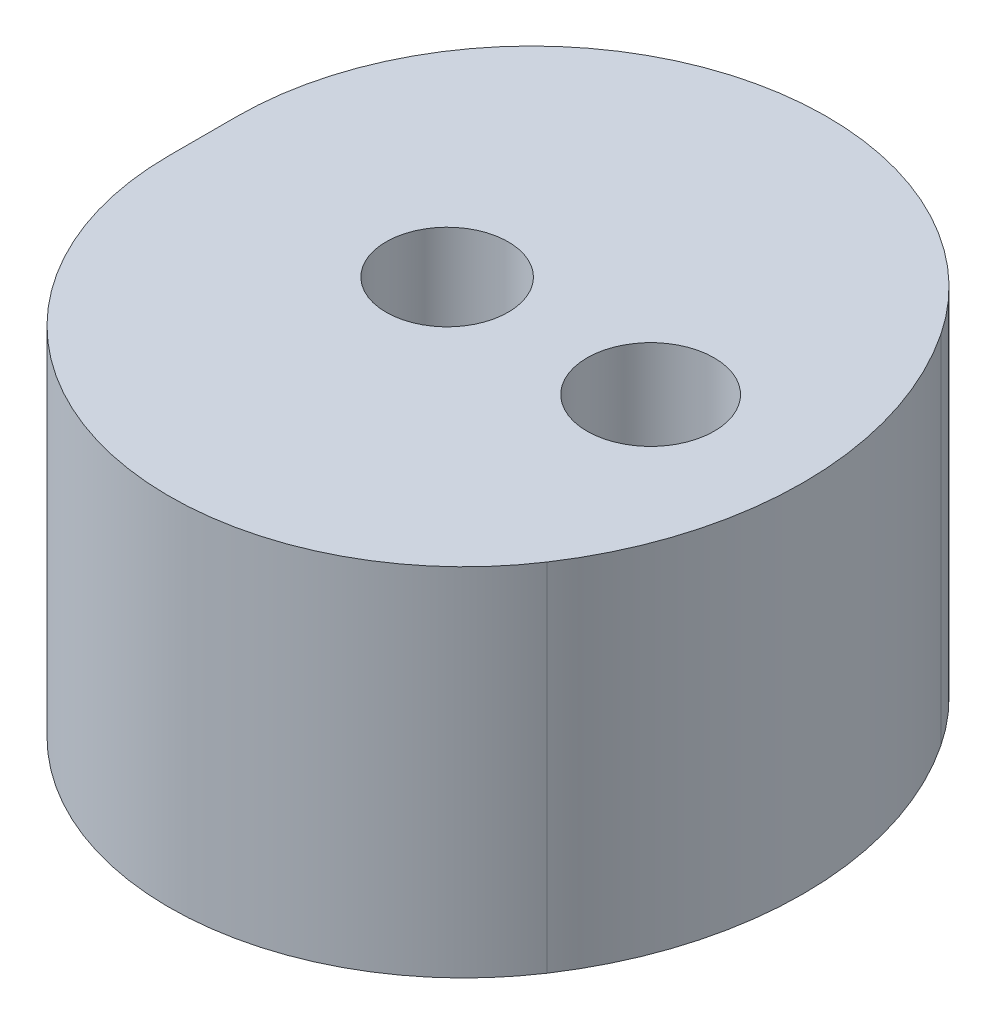
from build123d import *

# Parameters (mm, degrees)
SKETCH1_R           = 1.2
SKETCH1_R_2         = 1.25
BOSS_EXTRUDE1_DEPTH = 7
SKETCH3_R           = 2.15
CUT_EXTRUDE3_DEPTH  = 3.5
FILLET1_R           = 5.8


with BuildPart() as part:
    # Sketch1 → Boss-Extrude1 (new body)
    with BuildSketch(Plane(origin=(0, 0, 0), x_dir=(1, 0, 0), z_dir=(0, 1, 0))):
        with BuildLine():
            Line((9.45, 19.218429014), (9.45, 9.028237652))
            ThreePointArc((9.45, 9.028237652), (21.25, 14.123333333), (9.45, 19.218429014))
        make_face()
        with Locations((14.25, 14.123333333)):
            Circle(SKETCH1_R, mode=Mode.SUBTRACT)
        with Locations((18.25, 14.123333333)):
            Circle(SKETCH1_R_2, mode=Mode.SUBTRACT)
    extrude(amount=BOSS_EXTRUDE1_DEPTH)

    # Sketch3 → Cut-Extrude3 (cut)
    with BuildSketch(Plane.XZ):
        with Locations((18.25, -14.123333333)):
            Circle(SKETCH3_R)
    extrude(amount=-CUT_EXTRUDE3_DEPTH, mode=Mode.SUBTRACT)

    # Fillet1
    fillet1_edges = [part.edges().sort_by_distance(p)[0] for p in [
        (9.45, 3.5, -9.028237652),
        (9.45, 3.5, -19.218429014),
    ]]
    fillet(fillet1_edges, radius=FILLET1_R)


solid = part.part
